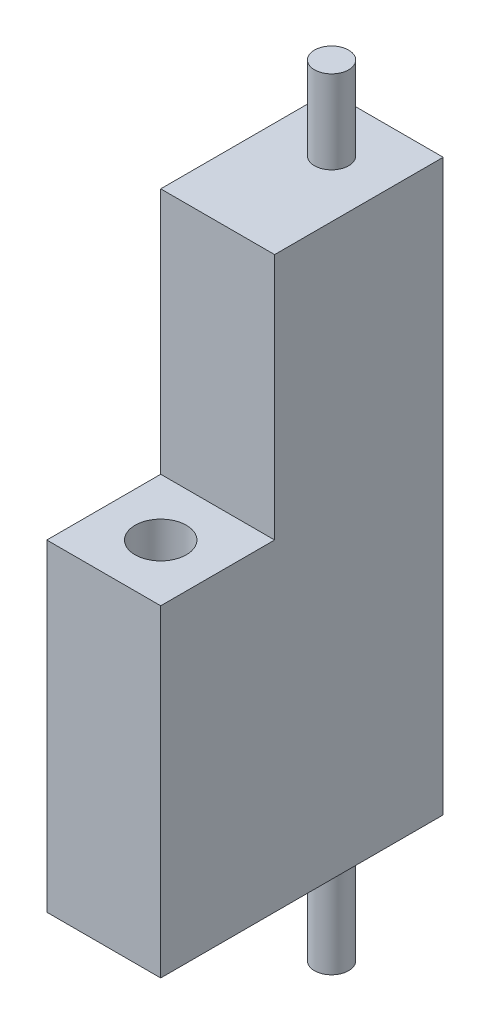
from build123d import *

# Parameters (mm, degrees)
EXTRUDE_START         = -250
SKETCH_3_R            = 50
SKETCH_3_R_2          = 32.5
EXTRUDE_1_DEPTH       = 250
EXTRUDE_7_DEPTH       = 250
EXTRUDE_8_DEPTH       = 50
EXTRUDE_8_DEPTH_BACK  = 50
SKETCH_12_W           = 100
SKETCH_12_H           = 500
EXTRUDE_10_DEPTH      = 148
EXTRUDE_12_DEPTH      = 73
EXTRUDE_12_DEPTH_BACK = 612
SKETCH_13_R           = 15
SKETCH_20_W           = 80
SKETCH_20_H           = 128
SKETCH_20_R           = 15
CUT_EXTRUDE_4_DEPTH   = 470
SKETCH_20_4_W         = 80
SKETCH_20_4_H         = 128
SKETCH_20_4_R         = 15
EXTRUDE_13_DEPTH      = 10
SKETCH_1_22_W         = 6
SKETCH_1_22_H         = 10
SKETCH_22_R           = 20.32
CUT_EXTRUDE_6_DEPTH   = 33
SKETCH_23_R           = 2
CUT_EXTRUDE_7_DEPTH   = 10
SKETCH_25_R           = 14
CUT_EXTRUDE_8_DEPTH   = 3
SKETCH_26_R           = 8.75
CUT_EXTRUDE_9_DEPTH   = 4
SKETCH_27_R           = 6
CUT_EXTRUDE_10_DEPTH  = 6
CUT_EXTRUDE_12_DEPTH  = 6


with BuildPart() as part:
    # 草图1 → 旋转1 (revolve)
    with BuildSketch(Plane.XY):
        Polygon((16.5, 10), (1, 10), (1, 102), (0, 102), (0, 250), (-10, 250), (-10, 0), (16.5, 0), align=None)
        Polygon((28.5, 10), (28.5, 0), (55, 0), (55, 250), (45, 250), (45, 102), (44, 102), (44, 10), align=None)
    revolve(axis=Axis((22.5, 0, 0), (0, 1, 0)))

    # 草图3 → 凸台-拉伸1 (add)
    with BuildSketch(Plane(origin=(0, 250, 0), x_dir=(1, 0, 0), z_dir=(0, 1, 0)).offset(EXTRUDE_START)):
        with Locations((22.5, 0)):
            Circle(SKETCH_3_R)
        with Locations((22.5, 0)):
            Circle(SKETCH_3_R_2, mode=Mode.SUBTRACT)
    extrude(amount=EXTRUDE_1_DEPTH)

    # 草图3<5> → 凸台-拉伸7 (add)
    with BuildSketch(Plane(origin=(0, 250, 0), x_dir=(1, 0, 0), z_dir=(0, 1, 0)).offset(EXTRUDE_START)):
        with BuildLine():
            ThreePointArc((22.5, -50), (-12.855339059, -35.355339059), (-27.5, 0))
            Line((-27.5, 0), (-27.5, -50))
            Line((-27.5, -50), (22.5, -50))
        make_face()
        with BuildLine():
            Line((-27.5, 50), (-27.5, 0))
            ThreePointArc((-27.5, 0), (-12.855339059, 35.355339059), (22.5, 50))
            Line((22.5, 50), (-27.5, 50))
        make_face()
        with BuildLine():
            Line((72.5, 50), (22.5, 50))
            ThreePointArc((22.5, 50), (57.855339059, 35.355339059), (72.5, 0))
            Line((72.5, 0), (72.5, 50))
        make_face()
        with BuildLine():
            ThreePointArc((72.5, 0), (57.855339059, -35.355339059), (22.5, -50))
            Line((22.5, -50), (72.5, -50))
            Line((72.5, -50), (72.5, 0))
        make_face()
    extrude(amount=EXTRUDE_7_DEPTH)

    # 草图1<21> → 凸台-拉伸8 (add, two sides: drawn at the far end of the back side and taken through both)
    with BuildSketch(Plane.XY.offset(-EXTRUDE_8_DEPTH_BACK)):
        Polygon((16.5, 0), (0, 0), (-10, 0), (-27.5, 0), (-27.5, -33), (72.5, -33), (72.5, 0), (55, 0), (45, 0), (28.5, 0), align=None)
    extrude(amount=EXTRUDE_8_DEPTH + EXTRUDE_8_DEPTH_BACK)

    # 草图12 → 凸台-拉伸10 (add)
    with BuildSketch(Plane(origin=(0, 0, -50), x_dir=(-1, 0, 0), z_dir=(0, 0, -1))):
        with Locations((-22.5, 217)):
            Rectangle(SKETCH_12_W, SKETCH_12_H)
    extrude(amount=EXTRUDE_10_DEPTH)

    # 草图13 → 凸台-拉伸12 (add, two sides: drawn at the far end of the back side and taken through both)
    with BuildSketch(Plane(origin=(0, 467, 0), x_dir=(1, 0, 0), z_dir=(0, 1, 0)).offset(-EXTRUDE_12_DEPTH_BACK)):
        with Locations((22.5, 150)):
            Circle(SKETCH_13_R)
    extrude(amount=EXTRUDE_12_DEPTH + EXTRUDE_12_DEPTH_BACK)

    # 草图20 → 切除-拉伸4 (cut)
    with BuildSketch(Plane.XZ.offset(33)):
        with Locations((22.5, -124)):
            Rectangle(SKETCH_20_W, SKETCH_20_H)
        with Locations((22.5, -150)):
            Circle(SKETCH_20_R, mode=Mode.SUBTRACT)
    extrude(amount=-CUT_EXTRUDE_4_DEPTH, mode=Mode.SUBTRACT)

    # 草图20<4> → 凸台-拉伸13 (add)
    with BuildSketch(Plane.XZ.offset(33)):
        with Locations((22.5, -124)):
            Rectangle(SKETCH_20_4_W, SKETCH_20_4_H)
        with Locations((22.5, -150)):
            Circle(SKETCH_20_4_R, mode=Mode.SUBTRACT)
    extrude(amount=-EXTRUDE_13_DEPTH)

    # 草图1<22> → 旋转2 (revolve)
    with BuildSketch(Plane.XY):
        with Locations((19.5, 5)):
            Rectangle(SKETCH_1_22_W, SKETCH_1_22_H)
    revolve(axis=Axis((22.5, 0, 0), (0, 1, 0)))

    # 草图22 → 切除-拉伸6 (cut)
    with BuildSketch(Plane.XZ.offset(33)):
        with Locations((22.5, 0)):
            Circle(SKETCH_22_R)
    extrude(amount=-CUT_EXTRUDE_6_DEPTH, mode=Mode.SUBTRACT)

    # 草图23 → 切除-拉伸7 (cut)
    with BuildSketch(Plane.XZ):
        with Locations((22.5, 17.5)):
            Circle(SKETCH_23_R)
        with Locations((34.874368671, 12.374368671)):
            Circle(SKETCH_23_R)
        with Locations((40, 0)):
            Circle(SKETCH_23_R)
        with Locations((34.874368671, -12.374368671)):
            Circle(SKETCH_23_R)
        with Locations((22.5, -17.5)):
            Circle(SKETCH_23_R)
        with Locations((10.125631329, -12.374368671)):
            Circle(SKETCH_23_R)
        with Locations((5, 0)):
            Circle(SKETCH_23_R)
        with Locations((10.125631329, 12.374368671)):
            Circle(SKETCH_23_R)
    extrude(amount=-CUT_EXTRUDE_7_DEPTH, mode=Mode.SUBTRACT)

    # 草图25 → 切除-拉伸8 (cut)
    with BuildSketch(Plane(origin=(0, 10, 0), x_dir=(1, 0, 0), z_dir=(0, 1, 0))):
        with Locations((22.5, 0)):
            Circle(SKETCH_25_R)
    extrude(amount=-CUT_EXTRUDE_8_DEPTH, mode=Mode.SUBTRACT)

    # 草图26 → 切除-拉伸9 (cut)
    with BuildSketch(Plane(origin=(0, 10, 0), x_dir=(1, 0, 0), z_dir=(0, 1, 0))):
        with Locations((22.5, 0)):
            Circle(SKETCH_26_R)
    extrude(amount=-CUT_EXTRUDE_9_DEPTH, mode=Mode.SUBTRACT)

    # 草图27 → 切除-拉伸10 (cut)
    with BuildSketch(Plane.XZ):
        with Locations((22.5, 0)):
            Circle(SKETCH_27_R)
    extrude(amount=-CUT_EXTRUDE_10_DEPTH, mode=Mode.SUBTRACT)

    # 草图27<5> → 切除-拉伸12 (cut)
    with BuildSketch(Plane.XZ):
        with BuildLine():
            Line((20.5, -8), (24.5, -8))
            Line((24.5, -8), (24.5, -5.656854249))
            ThreePointArc((24.5, -5.656854249), (22.5, -6), (20.5, -5.656854249))
            Line((20.5, -5.656854249), (20.5, -8))
        make_face()
    extrude(amount=-CUT_EXTRUDE_12_DEPTH, mode=Mode.SUBTRACT)


solid = part.part
